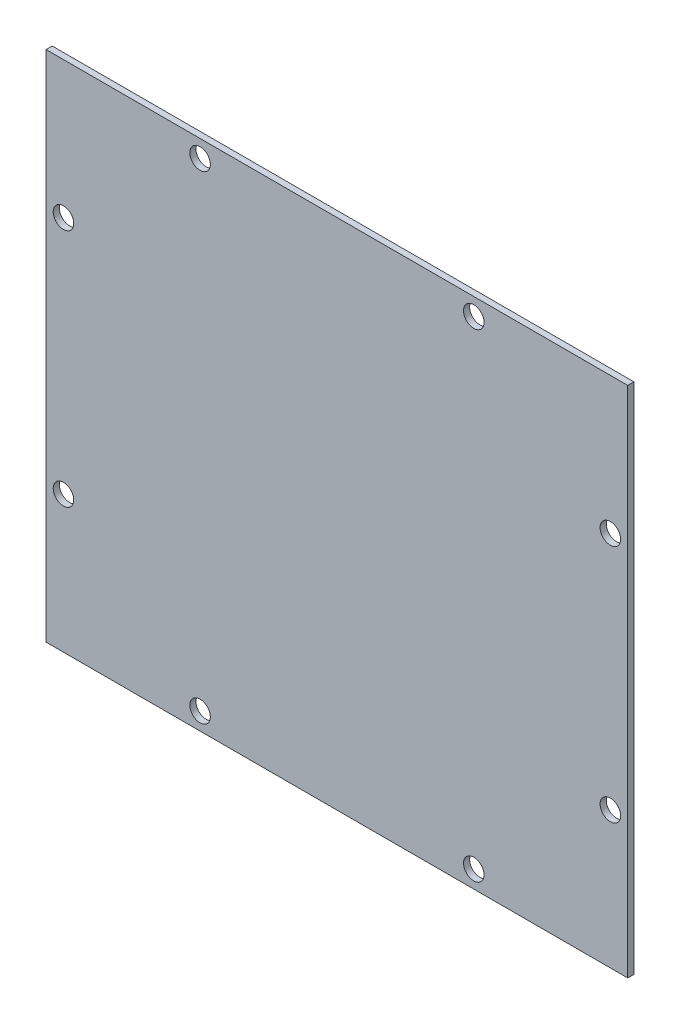
from build123d import *

# Parameters (mm, degrees)
SKETCH1_W               = 425
SKETCH1_H               = 375
BOSS_EXTRUDE1_DEPTH     = 4.5
SKETCH2_R               = 7.5
CUT_EXTRUDE1_DEPTH      = 1
CUT_EXTRUDE1_DEPTH_BACK = 5.5


with BuildPart() as part:
    # Sketch1 → Boss-Extrude1 (new body)
    with BuildSketch(Plane.XY):
        Rectangle(SKETCH1_W, SKETCH1_H)
    extrude(amount=-BOSS_EXTRUDE1_DEPTH)

    # Sketch2 → Cut-Extrude1 (cut, two sides)
    with BuildSketch(Plane.XY) as cut_extrude1_sk:
        with Locations((-199.8, 87.5)):
            Circle(SKETCH2_R)
        with Locations((-100, 174.8)):
            Circle(SKETCH2_R)
        with Locations((100, 174.8)):
            Circle(SKETCH2_R)
        with Locations((199.8, 87.5)):
            Circle(SKETCH2_R)
        with Locations((-100, -174.8)):
            Circle(SKETCH2_R)
        with Locations((-199.8, -87.5)):
            Circle(SKETCH2_R)
        with Locations((199.8, -87.5)):
            Circle(SKETCH2_R)
        with Locations((100, -174.8)):
            Circle(SKETCH2_R)
    extrude(amount=CUT_EXTRUDE1_DEPTH, mode=Mode.SUBTRACT)
    extrude(cut_extrude1_sk.sketch, amount=-CUT_EXTRUDE1_DEPTH_BACK, mode=Mode.SUBTRACT)


solid = part.part
